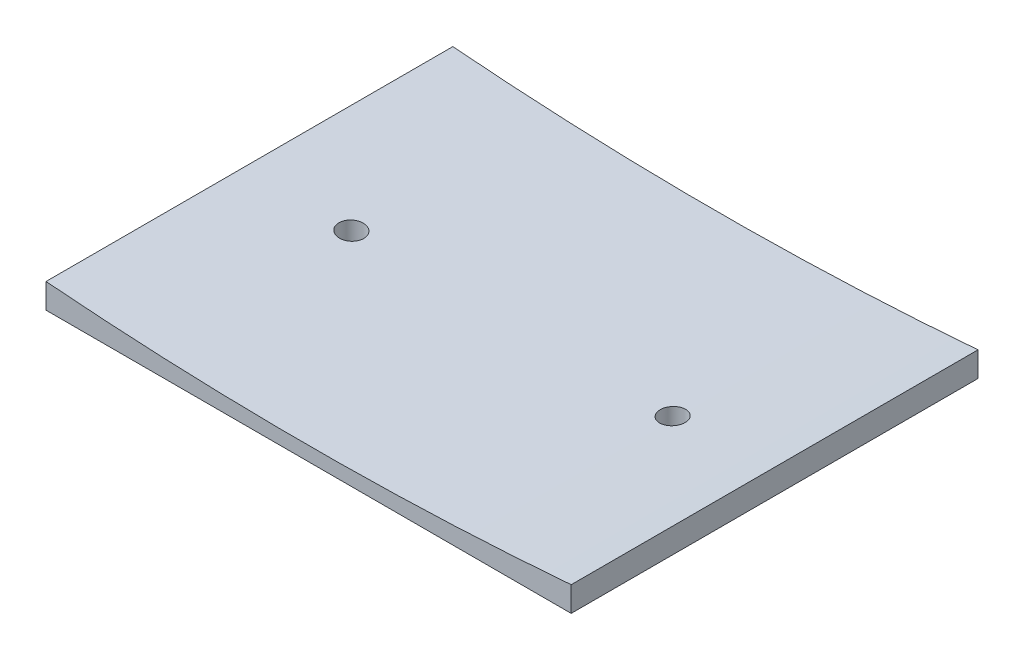
from build123d import *

# Parameters (mm, degrees)
CROQUIS1_W              = 52.8
CROQUIS1_H              = 40.9
SALIENTE_EXTRUIR1_DEPTH = 2.5
CORTAR_EXTRUIR1_DEPTH   = 44
CROQUIS3_R              = 1.25
CORTAR_EXTRUIR2_DEPTH   = 44


with BuildPart() as part:
    # Croquis1 → Saliente-Extruir1 (new body)
    with BuildSketch(Plane(origin=(0, 0, 0), x_dir=(1, 0, 0), z_dir=(0, 1, 0))):
        with Locations((7.799477352, -11.379703833)):
            Rectangle(CROQUIS1_W, CROQUIS1_H)
    extrude(amount=SALIENTE_EXTRUIR1_DEPTH)

    # Croquis2 → Cortar-Extruir1 (cut)
    with BuildSketch(Plane.XY.offset(31.829703833)):
        with BuildLine():
            Line((-18.600522648, 2.5), (34.199477352, 2.5))
            ThreePointArc((34.199477352, 2.5), (7.799477352, 1.421940601), (-18.600522648, 2.5))
        make_face()
    extrude(amount=-CORTAR_EXTRUIR1_DEPTH, mode=Mode.SUBTRACT)

    # Croquis3 → Cortar-Extruir2 (cut)
    with BuildSketch(Plane.XZ):
        with Locations((23.949477352, 11.379703833)):
            Circle(CROQUIS3_R)
        with Locations((-8.350522648, 11.379703833)):
            Circle(CROQUIS3_R)
    extrude(amount=-CORTAR_EXTRUIR2_DEPTH, mode=Mode.SUBTRACT)


solid = part.part
